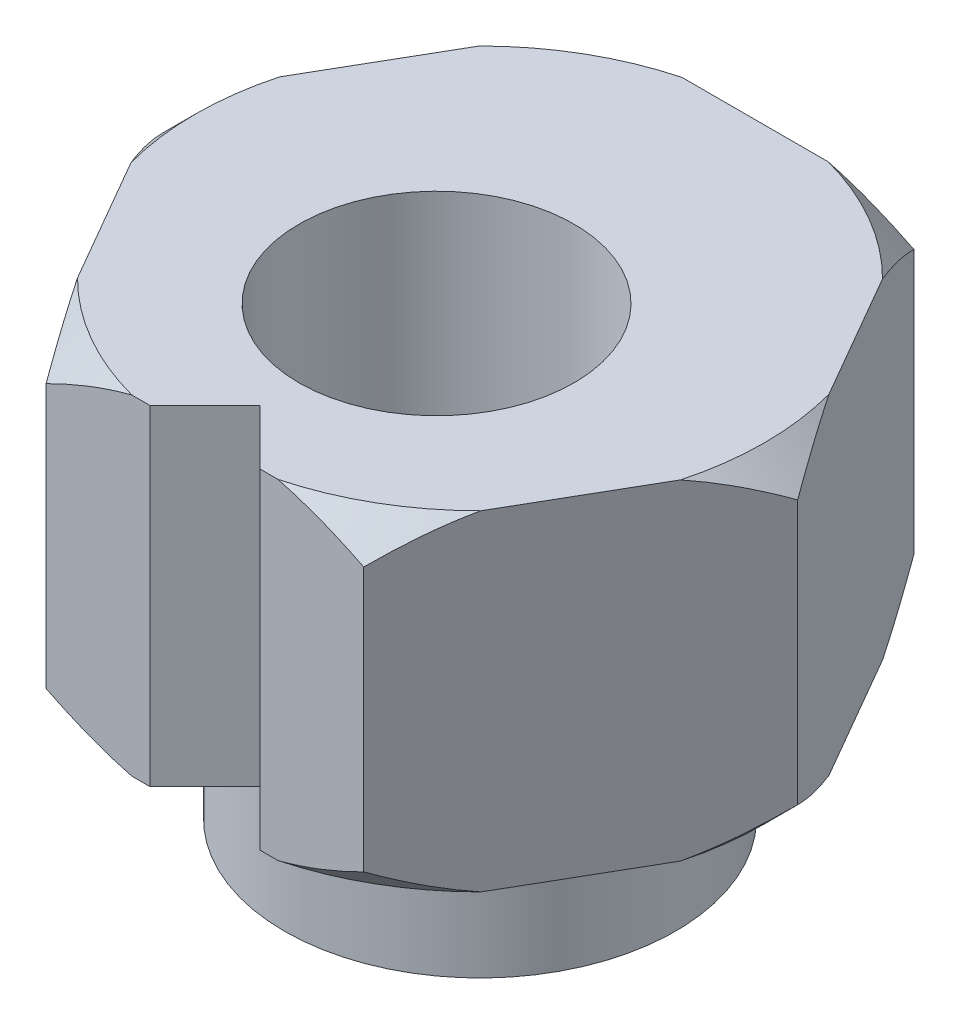
from build123d import *

# Parameters (mm, degrees)
BOSS_EXTRUDE1_DEPTH = 6
SKETCH3_R           = 3.555
BOSS_EXTRUDE3_DEPTH = 2.5
SKETCH4_R           = 2.5
CUT_EXTRUDE1_DEPTH  = 9.5
CUT_EXTRUDE2_DEPTH  = 7


with BuildPart() as part:
    # Sketch1 → Boss-Extrude1 (new body)
    with BuildSketch(Plane(origin=(0, 0, 0), x_dir=(1, 0, 0), z_dir=(0, 1, 0))):
        Polygon((5.773502692, 0), (2.886751346, 5), (-2.886751346, 5), (-5.773502692, 0), (-2.886751346, -5), (2.886751346, -5), align=None)
    extrude(amount=BOSS_EXTRUDE1_DEPTH)

    # Sketch3 → Boss-Extrude3 (add)
    with BuildSketch(Plane.XZ):
        Circle(SKETCH3_R)
    extrude(amount=BOSS_EXTRUDE3_DEPTH)

    # Sketch4 → Cut-Extrude1 (cut, through all)
    with BuildSketch(Plane(origin=(0, 6, 0), x_dir=(1, 0, 0), z_dir=(0, 1, 0))):
        with Locations((0, -0.79)):
            Circle(SKETCH4_R)
    extrude(amount=-CUT_EXTRUDE1_DEPTH, mode=Mode.SUBTRACT)

    # Sketch5 → Cut-Extrude2 (cut, through all)
    with BuildSketch(Plane(origin=(0, 0, 0), x_dir=(-1, 0, 0), z_dir=(0, -1, 0))):
        Polygon((-1, -5), (1, -5), (0, -4), align=None)
    extrude(amount=-CUT_EXTRUDE2_DEPTH, mode=Mode.SUBTRACT)

    # Sketch6 → Cut-Revolve1 (revolve, cut)
    with BuildSketch(Plane.XY):
        Polygon((5.173502692, 6), (5.773502692, 6), (5.773502692, 5.4), align=None)
        Polygon((5.773502692, 0.6), (5.173502692, 0), (5.773502692, 0), align=None)
    revolve(axis=Axis((0, 0, 0), (0, 1, 0)), mode=Mode.SUBTRACT)


solid = part.part
